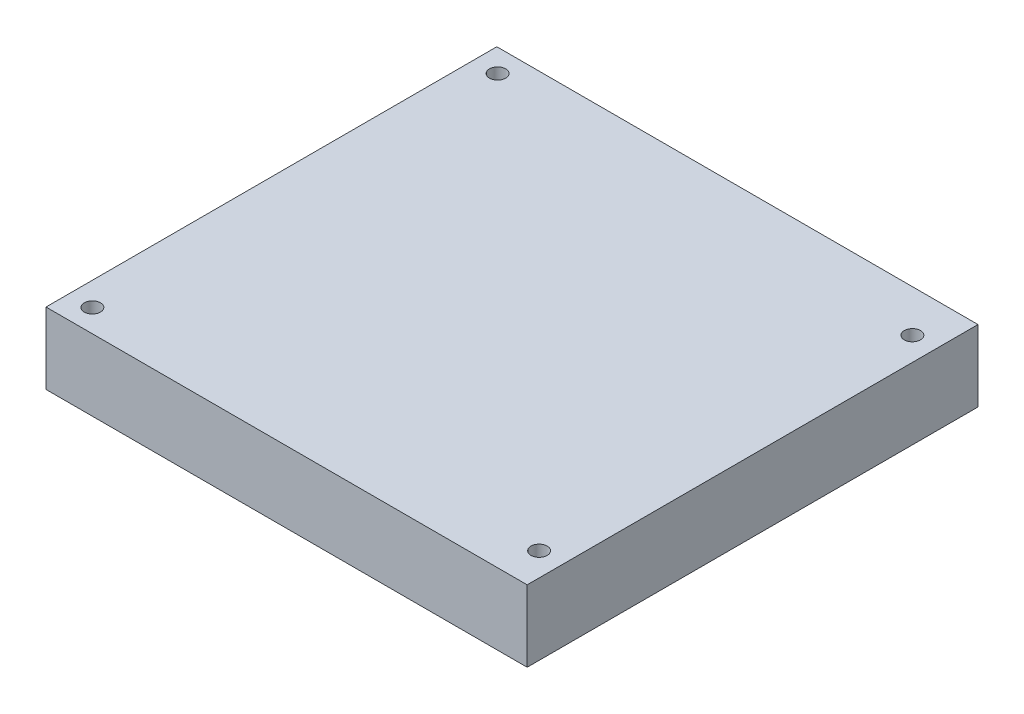
from build123d import *

# Parameters (mm, degrees)
SKETCH1_W           = 95
SKETCH1_H           = 89.01
SKETCH1_R           = 1.6
BOSS_EXTRUDE1_DEPTH = 14.1


with BuildPart() as part:
    # Sketch1 → Boss-Extrude1 (new body)
    with BuildSketch(Plane(origin=(0, 0, 0), x_dir=(1, 0, 0), z_dir=(0, 1, 0))):
        Rectangle(SKETCH1_W, SKETCH1_H)
        with Locations((-42.85, 40)):
            Circle(SKETCH1_R, mode=Mode.SUBTRACT)
        with Locations((42.85, 36.2)):
            Circle(SKETCH1_R, mode=Mode.SUBTRACT)
        with Locations((-42.85, -40)):
            Circle(SKETCH1_R, mode=Mode.SUBTRACT)
        with Locations((42.85, -37.5)):
            Circle(SKETCH1_R, mode=Mode.SUBTRACT)
    extrude(amount=BOSS_EXTRUDE1_DEPTH)


solid = part.part
